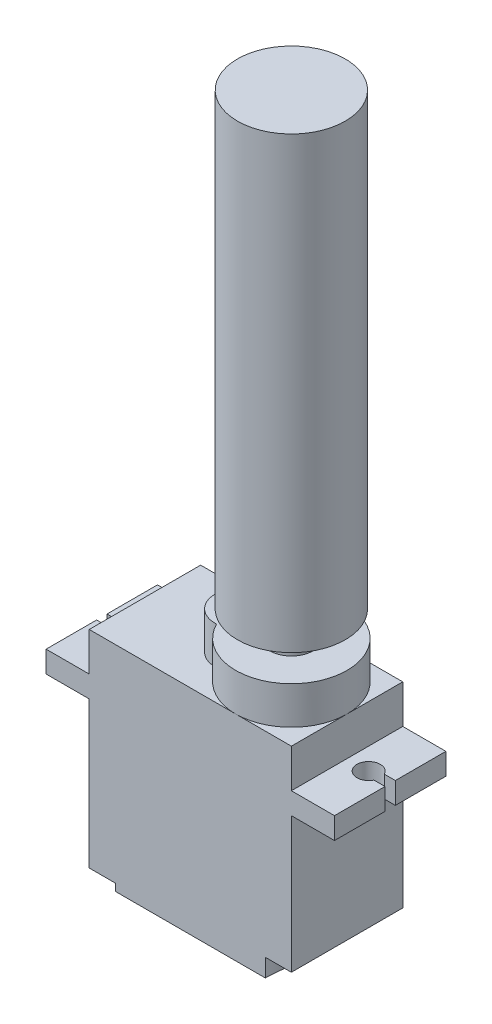
from build123d import *

# Parameters (mm, degrees)
SALIENTE_EXTRUIR1_DEPTH = 6.2
SALIENTE_EXTRUIR2_DEPTH = 4.2
CORTAR_EXTRUIR1_REACH   = 28.006
CORTAR_EXTRUIR3_DEPTH   = 0.8
CROQUIS4_5_W            = 1.5
CROQUIS4_5_H            = 3.75
CORTAR_EXTRUIR4_DEPTH   = 2
CORTAR_EXTRUIR5_DEPTH   = 26.895414652
CROQUIS7_R              = 2.425
CROQUIS7_R_2            = 0.875
SALIENTE_EXTRUIR4_DEPTH = 2.85
SKETCH1_R               = 6
BOSS_EXTRUDE1_DEPTH     = 50


with BuildPart() as part:
    # Croquis1 → Saliente-Extruir1 (new, symmetric)
    with BuildSketch(Plane.XY):
        Polygon((-11.25, 5.2), (-11.25, -11.9), (11.25, -11.9), (11.25, 5.2), (16.05, 5.2), (16.05, 7.6), (11.25, 7.6), (11.25, 11.9), (-11.25, 11.9), (-11.25, 7.6), (-16.05, 7.6), (-16.05, 5.2), align=None)
    extrude(amount=SALIENTE_EXTRUIR1_DEPTH, both=True)

    # Croquis2 → Saliente-Extruir2 (add)
    with BuildSketch(Plane(origin=(0, 11.9, 0), x_dir=(1, 0, 0), z_dir=(0, 1, 0))):
        with BuildLine():
            ThreePointArc((-0.484210526, -2.79508745), (11.25, 0), (-0.484210526, 2.79508745))
            ThreePointArc((-0.484210526, 2.79508745), (-3.45, 0), (-0.484210526, -2.79508745))
        make_face()
    extrude(amount=SALIENTE_EXTRUIR2_DEPTH)

    # Croquis3 → Cortar-Extruir1 (cut, up to next)
    with BuildSketch(Plane(origin=(0, 7.6, 0), x_dir=(1, 0, 0), z_dir=(0, 1, 0)), mode=Mode.PRIVATE) as cortar_extruir1_sk1:
        with BuildLine():
            Line((16.05, 0.575), (14.815922382, 0.575))
            ThreePointArc((14.815922382, 0.575), (12.35, 0), (14.815922382, -0.575))
            Line((14.815922382, -0.575), (16.05, -0.575))
            Line((16.05, -0.575), (16.05, 0.575))
        make_face()
    cortar_extruir1_tool1 = extrude(cortar_extruir1_sk1.sketch, amount=-CORTAR_EXTRUIR1_REACH, mode=Mode.PRIVATE) & part.part
    # Croquis3 → Cortar-Extruir1 (cut, up to next)
    with BuildSketch(Plane(origin=(0, 7.6, 0), x_dir=(1, 0, 0), z_dir=(0, 1, 0)), mode=Mode.PRIVATE) as cortar_extruir1_sk2:
        with BuildLine():
            Line((-16.05, 0.575), (-14.815922382, 0.575))
            ThreePointArc((-14.815922382, 0.575), (-12.35, 0), (-14.815922382, -0.575))
            Line((-14.815922382, -0.575), (-16.05, -0.575))
            Line((-16.05, -0.575), (-16.05, 0.575))
        make_face()
    cortar_extruir1_tool2 = extrude(cortar_extruir1_sk2.sketch, amount=-CORTAR_EXTRUIR1_REACH, mode=Mode.PRIVATE) & part.part
    add(cortar_extruir1_tool1.solids().sort_by_distance((14.012834, 7.6, 0))[0], mode=Mode.SUBTRACT)
    add(cortar_extruir1_tool2.solids().sort_by_distance((-14.012834, 7.6, 0))[0], mode=Mode.SUBTRACT)

    # Croquis4 → Cortar-Extruir3 (cut)
    with BuildSketch(Plane.XZ.offset(11.9)):
        with BuildLine():
            Line((-11.25, 6.2), (-11.25, 3.3))
            ThreePointArc((-11.25, 3.3), (-9.199390335, 4.149390335), (-8.35, 6.2))
            Line((-8.35, 6.2), (-11.25, 6.2))
        make_face()
        with BuildLine():
            ThreePointArc((-8.35, -6.2), (-9.199390335, -4.149390335), (-11.25, -3.3))
            Line((-11.25, -3.3), (-11.25, -6.2))
            Line((-11.25, -6.2), (-8.35, -6.2))
        make_face()
    extrude(amount=-CORTAR_EXTRUIR3_DEPTH, mode=Mode.SUBTRACT)

    # Croquis4_5 → Cortar-Extruir4 (cut)
    with BuildSketch(Plane.XZ.offset(11.9)):
        with BuildLine():
            Line((11.25, 6.2), (8.35, 6.2))
            ThreePointArc((8.35, 6.2), (9.199390335, 4.149390335), (11.25, 3.3))
            Line((11.25, 3.3), (11.25, 6.2))
        make_face()
        with BuildLine():
            ThreePointArc((11.25, -3.3), (9.199390335, -4.149390335), (8.35, -6.2))
            Line((8.35, -6.2), (11.25, -6.2))
            Line((11.25, -6.2), (11.25, -3.3))
        make_face()
        with Locations((10.5, 0)):
            Rectangle(CROQUIS4_5_W, CROQUIS4_5_H)
    extrude(amount=-CORTAR_EXTRUIR4_DEPTH, mode=Mode.SUBTRACT)

    # Croquis6 → Cortar-Extruir5 (cut, through all)
    with BuildSketch(Plane(origin=(0, 0, -6.2), x_dir=(-1, 0, 0), z_dir=(0, 0, -1))):
        Polygon((-11.25, -9.9), (-8.35, -11.9), (-11.25, -11.9), align=None)
    extrude(amount=-CORTAR_EXTRUIR5_DEPTH, mode=Mode.SUBTRACT)

    # Croquis7 → Saliente-Extruir4 (add)
    with BuildSketch(Plane(origin=(0, 16.1, 0), x_dir=(1, 0, 0), z_dir=(0, 1, 0))):
        with Locations((5.05, 0)):
            Circle(CROQUIS7_R)
        with Locations((5.05, 0)):
            Circle(CROQUIS7_R_2, mode=Mode.SUBTRACT)
    extrude(amount=SALIENTE_EXTRUIR4_DEPTH)

    # Sketch1 → Boss-Extrude1 (add)
    with BuildSketch(Plane(origin=(0, 18.95, 0), x_dir=(1, 0, 0), z_dir=(0, 1, 0))):
        with Locations((5.05, 0)):
            Circle(SKETCH1_R)
    extrude(amount=BOSS_EXTRUDE1_DEPTH)


solid = part.part
